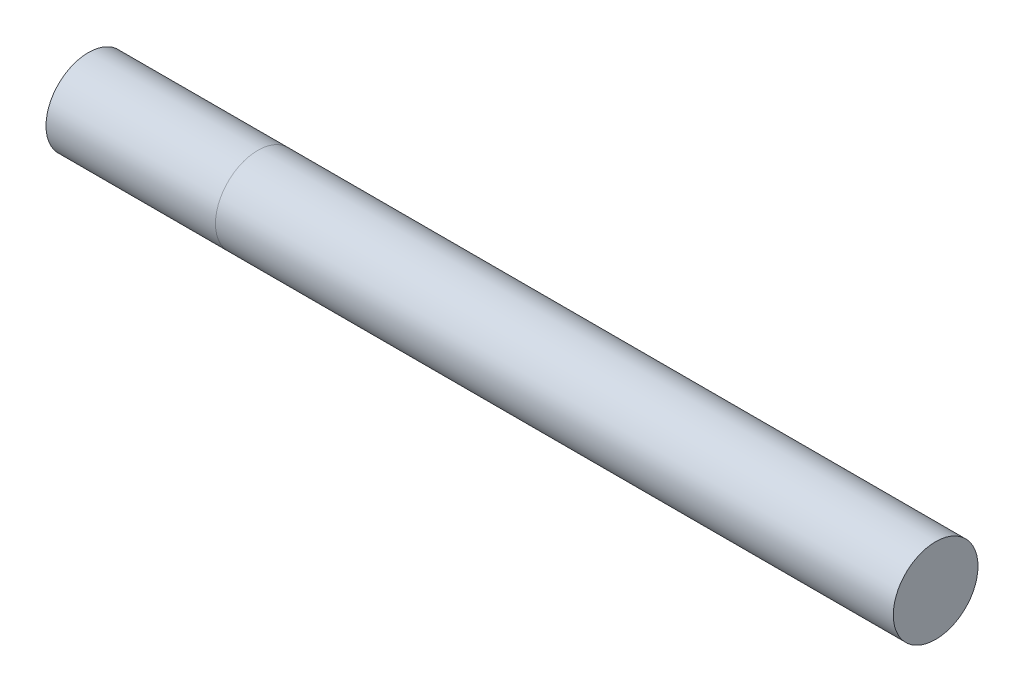
from build123d import *

# Parameters (mm, degrees)
SKETCH1_R           = 12.5
BOSS_EXTRUDE1_DEPTH = 250


with BuildPart() as part:
    # Sketch1 → Boss-Extrude1 (new body)
    with BuildSketch(Plane(origin=(0, 0, 0), x_dir=(0, 0, -1), z_dir=(1, 0, 0))):
        Circle(SKETCH1_R)
    extrude(amount=BOSS_EXTRUDE1_DEPTH)


solid = part.part
